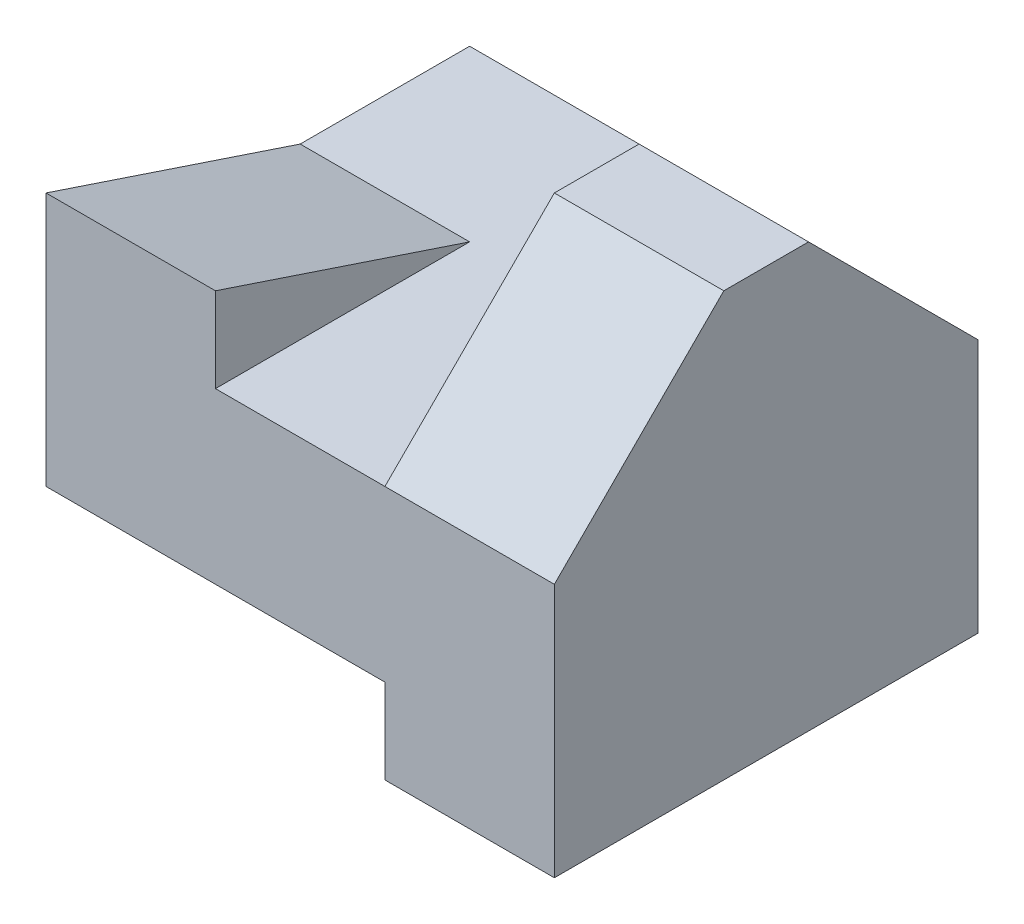
from build123d import *

# Parameters (mm, degrees)
SKETCH1_W           = 30
SKETCH1_H           = 25
BOSS_EXTRUDE1_DEPTH = 25
CUT_EXTRUDE1_DEPTH  = 10
SKETCH3_W           = 10
SKETCH3_H           = 5
CUT_EXTRUDE2_DEPTH  = 30
CUT_EXTRUDE3_DEPTH  = 30
CUT_EXTRUDE5_DEPTH  = 10
SKETCH7_W           = 10
SKETCH7_H           = 10
CUT_EXTRUDE6_DEPTH  = 5


with BuildPart() as part:
    # Sketch1 → Boss-Extrude1 (new body)
    with BuildSketch(Plane.XY):
        with Locations((15, 12.5)):
            Rectangle(SKETCH1_W, SKETCH1_H)
    extrude(amount=BOSS_EXTRUDE1_DEPTH)

    # Sketch2 → Cut-Extrude1 (cut)
    with BuildSketch(Plane(origin=(30, 0, 0), x_dir=(0, 0, -1), z_dir=(1, 0, 0))):
        Polygon((-25, 25), (-25, 15), (-15, 25), align=None)
        Polygon((-10, 25), (0, 25), (0, 15), align=None)
    extrude(amount=-CUT_EXTRUDE1_DEPTH, mode=Mode.SUBTRACT)

    # Sketch3 → Cut-Extrude2 (cut)
    with BuildSketch(Plane.XY.offset(25)):
        with Locations((15, 2.5)):
            Rectangle(SKETCH3_W, SKETCH3_H)
    extrude(amount=-CUT_EXTRUDE2_DEPTH, mode=Mode.SUBTRACT)

    # Sketch4 → Cut-Extrude3 (cut)
    with BuildSketch(Plane.XY.offset(25)):
        Polygon((0, 25), (20, 25), (20, 15), (10, 15), (10, 20), (0, 20), align=None)
    extrude(amount=-CUT_EXTRUDE3_DEPTH, mode=Mode.SUBTRACT)

    # Sketch6 → Cut-Extrude5 (cut)
    with BuildSketch(Plane.ZY):
        Polygon((25, 20), (10, 15), (10, 20), align=None)
        Polygon((25, 0), (10, 0), (25, 5), align=None)
    extrude(amount=-CUT_EXTRUDE5_DEPTH, mode=Mode.SUBTRACT)

    # Sketch7 → Cut-Extrude6 (cut)
    with BuildSketch(Plane(origin=(0, 20, 0), x_dir=(1, 0, 0), z_dir=(0, 1, 0))):
        with Locations((5, -5)):
            Rectangle(SKETCH7_W, SKETCH7_H)
    extrude(amount=-CUT_EXTRUDE6_DEPTH, mode=Mode.SUBTRACT)


solid = part.part
